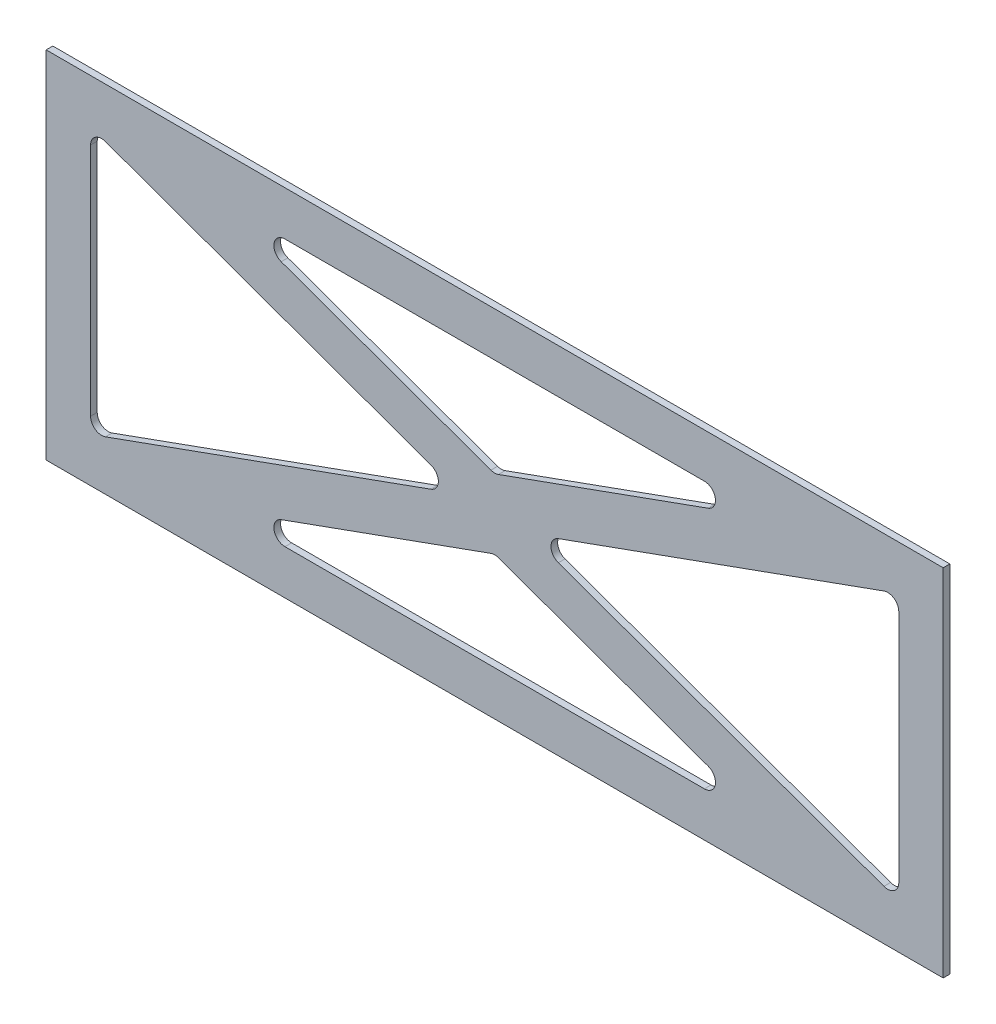
from build123d import *

# Parameters (mm, degrees)
SKETCH1_W           = 404
SKETCH1_H           = 160
BOSS_EXTRUDE1_DEPTH = 3


with BuildPart() as part:
    # Sketch1 → Boss-Extrude1 (new body)
    with BuildSketch(Plane.XY.offset(152)):
        with Locations((134.5, -85.941341737)):
            Rectangle(SKETCH1_W, SKETCH1_H)
        with BuildLine():
            Line((-47.5, -138.822974494), (-47.5, -33.059708979))
            ThreePointArc((-47.5, -33.059708979), (-45.373921063, -28.968183869), (-40.80376891, -28.356220902))
            Line((-40.80376891, -28.356220902), (105.831987613, -81.23785366))
            ThreePointArc((105.831987613, -81.23785366), (109.135756522, -85.941341737), (105.831987613, -90.644829813))
            Line((105.831987613, -90.644829813), (-40.80376891, -143.526462571))
            ThreePointArc((-40.80376891, -143.526462571), (-45.373921063, -142.914499604), (-47.5, -138.822974494))
        make_face(mode=Mode.SUBTRACT)
        with BuildLine():
            Line((228.942684704, -25.941341737), (40.057315296, -25.941341737))
            ThreePointArc((40.057315296, -25.941341737), (35.132001073, -30.080365658), (38.361084206, -35.644829813))
            Line((38.361084206, -35.644829813), (132.80376891, -69.703939867))
            ThreePointArc((132.80376891, -69.703939867), (134.5, -70.00045179), (136.19623109, -69.703939867))
            Line((136.19623109, -69.703939867), (230.638915794, -35.644829813))
            ThreePointArc((230.638915794, -35.644829813), (233.867998927, -30.080365658), (228.942684704, -25.941341737))
        make_face(mode=Mode.SUBTRACT)
        with BuildLine():
            Line((309.80376891, -28.356220902), (163.168012387, -81.23785366))
            ThreePointArc((163.168012387, -81.23785366), (159.864243478, -85.941341737), (163.168012387, -90.644829813))
            Line((163.168012387, -90.644829813), (309.80376891, -143.526462571))
            ThreePointArc((309.80376891, -143.526462571), (314.373921063, -142.914499604), (316.5, -138.822974494))
            Line((316.5, -138.822974494), (316.5, -33.059708979))
            ThreePointArc((316.5, -33.059708979), (314.373921063, -28.968183869), (309.80376891, -28.356220902))
        make_face(mode=Mode.SUBTRACT)
        with BuildLine():
            Line((38.361084206, -136.23785366), (132.80376891, -102.178743606))
            ThreePointArc((132.80376891, -102.178743606), (134.5, -101.882231683), (136.19623109, -102.178743606))
            Line((136.19623109, -102.178743606), (230.638915794, -136.23785366))
            ThreePointArc((230.638915794, -136.23785366), (233.867998927, -141.802317815), (228.942684704, -145.941341737))
            Line((228.942684704, -145.941341737), (40.057315296, -145.941341737))
            ThreePointArc((40.057315296, -145.941341737), (35.132001073, -141.802317815), (38.361084206, -136.23785366))
        make_face(mode=Mode.SUBTRACT)
    extrude(amount=BOSS_EXTRUDE1_DEPTH)


solid = part.part
